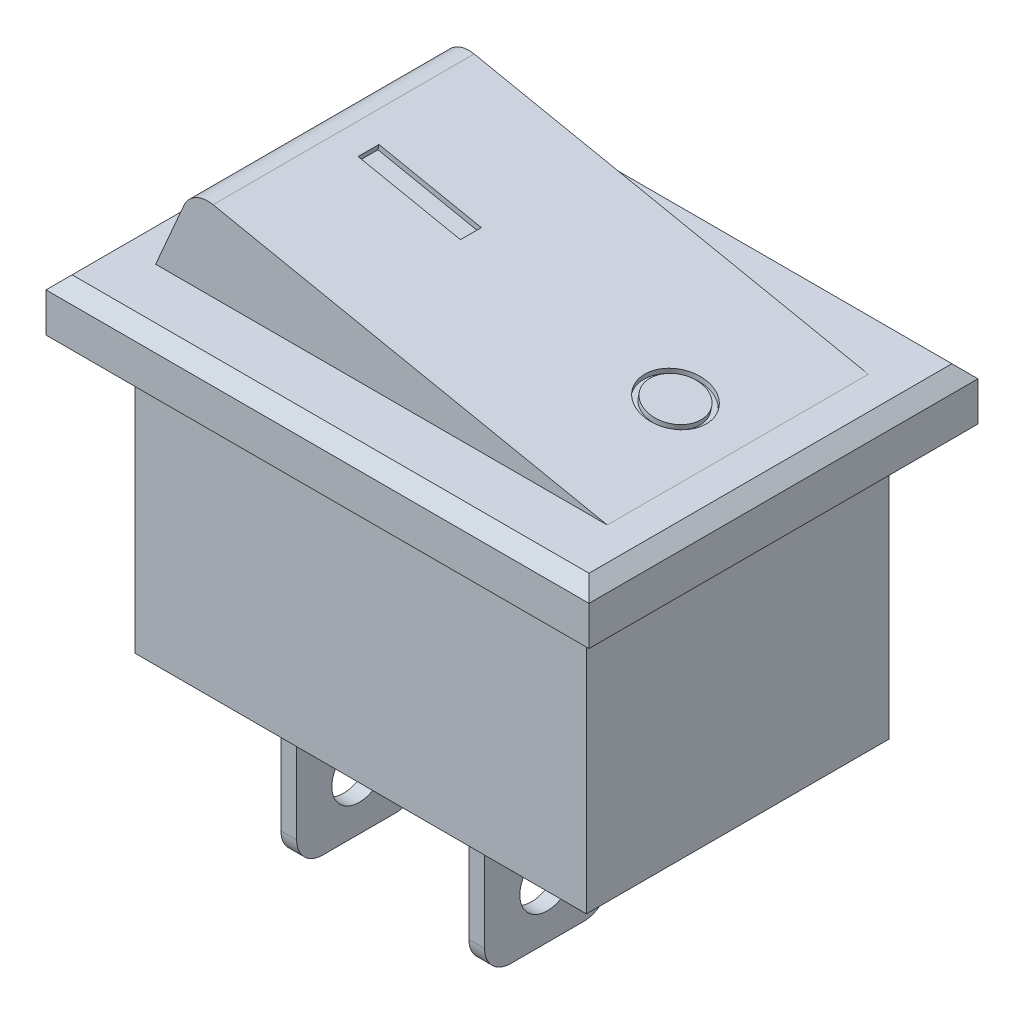
from build123d import *

# Parameters (mm, degrees)
SKETCH_1_W          = 17.3
SKETCH_1_H          = 11.6
EXTRUDE_1_DEPTH     = 10.5
SKETCH_2_W          = 20.8
SKETCH_2_H          = 14.9
EXTRUDE_2_DEPTH     = 2
CHAMFER_1_SIZE      = 0.5
SKETCH_3_W          = 0.6
SKETCH_3_H          = 4.8
EXTRUDE_3_DEPTH     = 7.5
SKETCH_4_R          = 1.05
CUT_EXTRUDE_1_DEPTH = 17.85
FILLET_1_R          = 1
EXTRUDE_4_DEPTH     = 5
SKETCH_7_R          = 1.2
SKETCH_7_R_2        = 1
SKETCH_7_W          = 4
SKETCH_7_H          = 0.8
CUT_EXTRUDE_2_DEPTH = 0.2


with BuildPart() as part:
    # 草图1 → 凸台-拉伸1 (new body)
    with BuildSketch(Plane(origin=(0, 0, 0), x_dir=(1, 0, 0), z_dir=(0, 1, 0))):
        Rectangle(SKETCH_1_W, SKETCH_1_H)
    extrude(amount=EXTRUDE_1_DEPTH)

    # 草图2 → 凸台-拉伸2 (add)
    with BuildSketch(Plane(origin=(0, 10.5, 0), x_dir=(1, 0, 0), z_dir=(0, 1, 0))):
        Rectangle(SKETCH_2_W, SKETCH_2_H)
    extrude(amount=EXTRUDE_2_DEPTH)

    # 倒角1
    chamfer_1_edges = [part.edges().sort_by_distance(p)[0] for p in [
        (10.4, 12.5, 0),
        (0, 12.5, -7.45),
        (-10.4, 12.5, 0),
        (0, 12.5, 7.45),
    ]]
    chamfer(chamfer_1_edges, length=CHAMFER_1_SIZE)

    # 草图3 → 凸台-拉伸3 (add)
    with BuildSketch(Plane.XZ):
        with Locations((-6.15, 0)):
            Rectangle(SKETCH_3_W, SKETCH_3_H)
        with Locations((1.05, 0)):
            Rectangle(SKETCH_3_W, SKETCH_3_H)
    extrude(amount=EXTRUDE_3_DEPTH)

    # 草图4 → 切除-拉伸1 (cut, through all)
    with BuildSketch(Plane.ZY.offset(6.45)):
        with Locations((0, -5.4)):
            Circle(SKETCH_4_R)
    extrude(amount=-CUT_EXTRUDE_1_DEPTH, mode=Mode.SUBTRACT)

    # 圆角1
    fillet_1_edges = [part.edges().sort_by_distance(p)[0] for p in [
        (-6.15, -7.5, -2.4),
        (-6.15, -7.5, 2.4),
        (1.05, -7.5, -2.4),
        (1.05, -7.5, 2.4),
    ]]
    fillet(fillet_1_edges, radius=FILLET_1_R)

    # 草图6 → 凸台-拉伸4 (add, symmetric)
    with BuildSketch(Plane.XY):
        with BuildLine():
            Line((-8.65, 12.5), (-7.567226169, 14.993049988))
            ThreePointArc((-7.567226169, 14.993049988), (-7.111867175, 15.481632233), (-6.450485665, 15.574578036))
            Line((-6.450485665, 15.574578036), (8.65, 12.5))
            Line((8.65, 12.5), (9.9, 12.5))
            Line((9.9, 12.5), (10.4, 12))
            Line((10.4, 12), (-10.4, 12))
            Line((-10.4, 12), (-9.9, 12.5))
            Line((-9.9, 12.5), (-8.65, 12.5))
        make_face()
    extrude(amount=EXTRUDE_4_DEPTH, both=True)

    # 草图7 → 切除-拉伸2 (cut)
    with BuildSketch(Plane(origin=(2.788110156, 13.693527027, 0), x_dir=(0.979894908, -0.199514335, 0), z_dir=(0.199514335, 0.979894908, 0))):
        with Locations((3.54609821, 0)):
            Circle(SKETCH_7_R)
        with Locations((3.54609821, 0)):
            Circle(SKETCH_7_R_2, mode=Mode.SUBTRACT)
        with Locations((-6.42814964, -0.024521247)):
            Rectangle(SKETCH_7_W, SKETCH_7_H)
    extrude(amount=-CUT_EXTRUDE_2_DEPTH, mode=Mode.SUBTRACT)


solid = part.part
